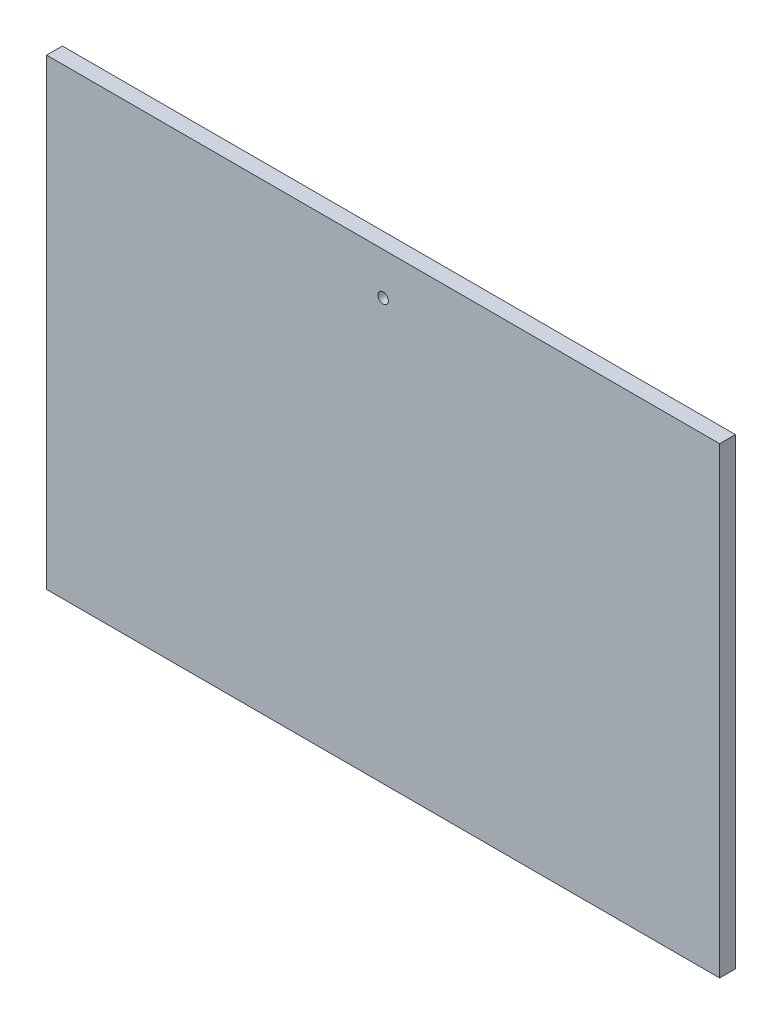
from build123d import *

# Parameters (mm, degrees)
SKETCH_1_W          = 64
SKETCH_1_H          = 50
SKETCH_1_R          = 0.5
EXTRUDE_1_DEPTH     = 1.5
SKETCH_2_W          = 64
SKETCH_2_H          = 3
CUT_EXTRUDE_1_DEPTH = 1.5


with BuildPart() as part:
    # 草图1 → 凸台-拉伸1 (new body)
    with BuildSketch(Plane.XY):
        with Locations((-27.218154809, 13.932786885)):
            Rectangle(SKETCH_1_W, SKETCH_1_H)
        with Locations((-27.218154809, 31.932786885)):
            Circle(SKETCH_1_R, mode=Mode.SUBTRACT)
    extrude(amount=EXTRUDE_1_DEPTH)

    # 草图2 → 切除-拉伸1 (cut)
    with BuildSketch(Plane.XY.offset(1.5)):
        with Locations((-27.218154809, -9.567213115)):
            Rectangle(SKETCH_2_W, SKETCH_2_H)
        with Locations((-27.218154809, 37.432786885)):
            Rectangle(SKETCH_2_W, SKETCH_2_H)
    extrude(amount=-CUT_EXTRUDE_1_DEPTH, mode=Mode.SUBTRACT)


solid = part.part
